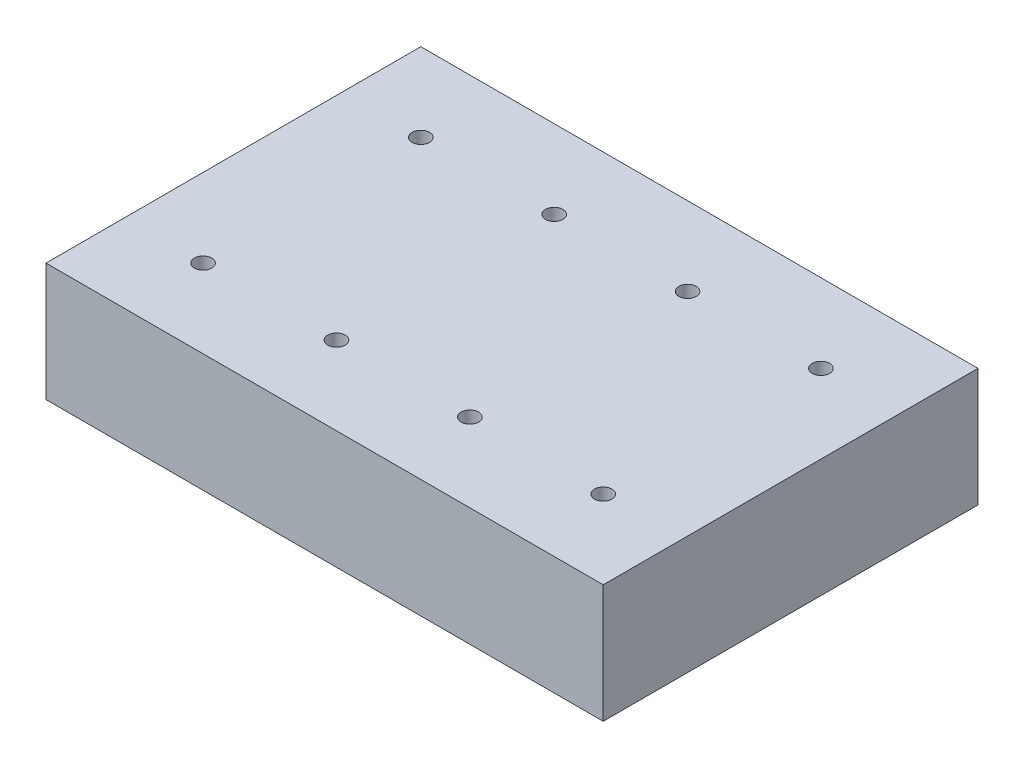
from build123d import *

# Parameters (mm, degrees)
SKETCH1_W           = 127.7
SKETCH1_H           = 85.9
BOSS_EXTRUDE1_DEPTH = 28.1
SKETCH2_R           = 13.9
CUT_EXTRUDE3_DEPTH  = 25
CHAMFER3_SIZE       = 1
CHAMFER4_SIZE       = 1
SKETCH3_R           = 13.9
CUT_EXTRUDE5_DEPTH  = 25
CHAMFER5_SIZE       = 1
CHAMFER6_SIZE       = 1
SKETCH5_R           = 2
CUT_EXTRUDE7_DEPTH  = 10


with BuildPart() as part:
    # Sketch1 → Boss-Extrude1 (new body)
    with BuildSketch(Plane(origin=(0, 0, 0), x_dir=(1, 0, 0), z_dir=(0, 1, 0))):
        with Locations((-248.856003869, 89.066665881)):
            Rectangle(SKETCH1_W, SKETCH1_H)
    extrude(amount=BOSS_EXTRUDE1_DEPTH)

    # Sketch2 → Cut-Extrude3 (cut)
    with BuildSketch(Plane(origin=(0, 0, 0), x_dir=(-1, 0, 0), z_dir=(0, -1, 0))):
        with Locations((294.706003869, 64.116665881)):
            Circle(SKETCH2_R)
        with Locations((264.136003869, 64.116665881)):
            Circle(SKETCH2_R)
        with Locations((233.566003869, 64.116665881)):
            Circle(SKETCH2_R)
        with Locations((203.006003869, 64.116665881)):
            Circle(SKETCH2_R)
    extrude(amount=-CUT_EXTRUDE3_DEPTH, mode=Mode.SUBTRACT)

    # Chamfer3
    chamfer3_edges = [part.edges().sort_by_distance(p)[0] for p in [
        (-250.236003869, 0, -64.116665881),
    ]]
    chamfer(chamfer3_edges, length=CHAMFER3_SIZE)

    # Chamfer4
    chamfer4_edges = [part.edges().sort_by_distance(p)[0] for p in [
        (-280.806003869, 0, -64.116665881),
        (-189.106003869, 0, -64.116665881),
        (-219.666003869, 0, -64.116665881),
    ]]
    chamfer(chamfer4_edges, length=CHAMFER4_SIZE)

    # Sketch3 → Cut-Extrude5 (cut)
    with BuildSketch(Plane.XZ):
        with Locations((-233.566003869, -114.016665881)):
            Circle(SKETCH3_R)
        with Locations((-264.136003869, -114.016665881)):
            Circle(SKETCH3_R)
        with Locations((-294.706003869, -114.016665881)):
            Circle(SKETCH3_R)
        with Locations((-203.006003869, -114.016665881)):
            Circle(SKETCH3_R)
    extrude(amount=-CUT_EXTRUDE5_DEPTH, mode=Mode.SUBTRACT)

    # Chamfer5
    chamfer5_edges = [part.edges().sort_by_distance(p)[0] for p in [
        (-308.606003869, 0, -114.016665881),
        (-278.036003869, 0, -114.016665881),
        (-216.906003869, 0, -114.016665881),
        (-247.466003869, 0, -114.016665881),
    ]]
    chamfer(chamfer5_edges, length=CHAMFER5_SIZE)

    # Chamfer6
    chamfer6_edges = [part.edges().sort_by_distance(p)[0] for p in [
        (-248.856003869, 0, -132.016665881),
        (-185.006003869, 0, -89.066665881),
        (-248.856003869, 0, -46.116665881),
        (-312.706003869, 0, -89.066665881),
    ]]
    chamfer(chamfer6_edges, length=CHAMFER6_SIZE)

    # Sketch5 → Cut-Extrude7 (cut)
    with BuildSketch(Plane(origin=(0, 25, 0), x_dir=(-1, 0, 0), z_dir=(0, -1, 0))):
        with Locations((294.706003869, 64.116665881)):
            Circle(SKETCH5_R)
        with Locations((264.136003869, 64.116665881)):
            Circle(SKETCH5_R)
        with Locations((233.566003869, 64.116665881)):
            Circle(SKETCH5_R)
        with Locations((203.006003869, 64.116665881)):
            Circle(SKETCH5_R)
        with Locations((294.706003869, 114.016665881)):
            Circle(SKETCH5_R)
        with Locations((264.136003869, 114.016665881)):
            Circle(SKETCH5_R)
        with Locations((233.566003869, 114.016665881)):
            Circle(SKETCH5_R)
        with Locations((203.006003869, 114.016665881)):
            Circle(SKETCH5_R)
    extrude(amount=-CUT_EXTRUDE7_DEPTH, mode=Mode.SUBTRACT)


solid = part.part
